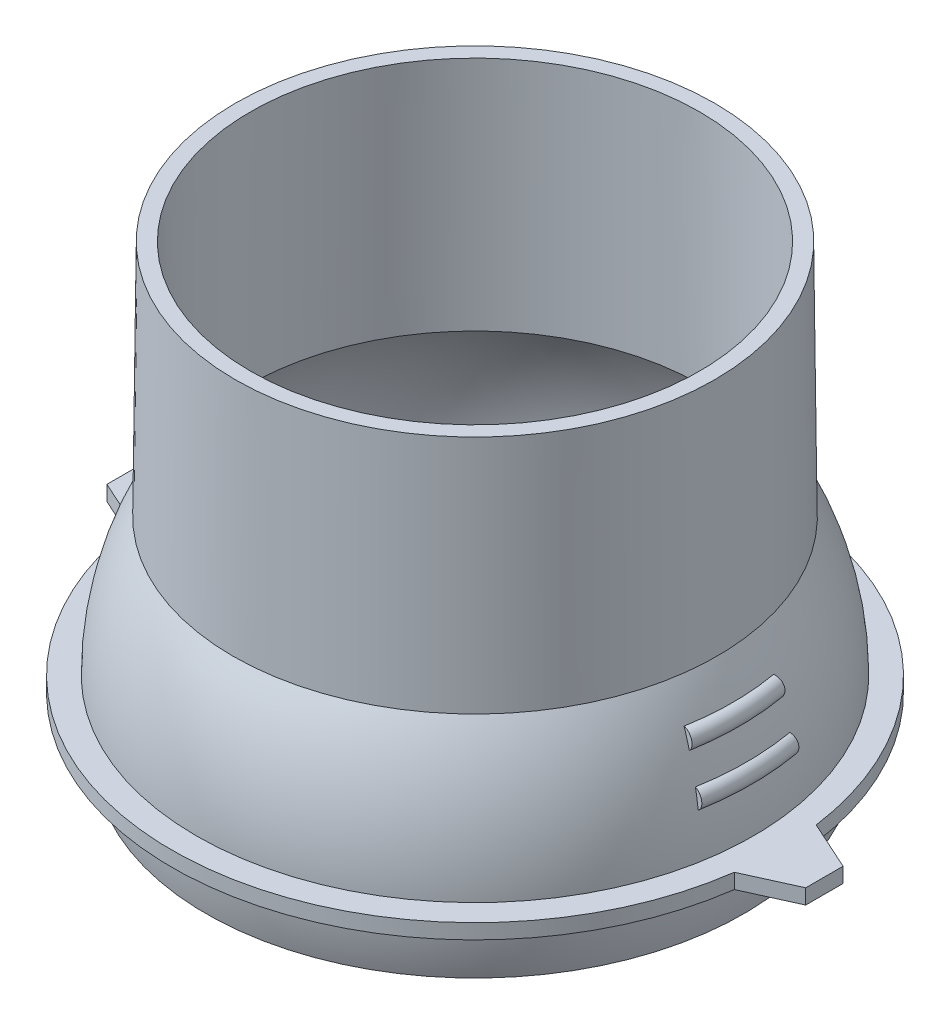
from build123d import *

# Parameters (mm, degrees)
BOSS_EXTRUDE1_DEPTH = 3
REVOLVE3_ANGLE      = 20


with BuildPart() as part:
    # Sketch2 → Revolve1 (revolve)
    with BuildSketch(Plane(origin=(0, 0, 0), x_dir=(0, 0, -1), z_dir=(1, 0, 0))):
        with BuildLine():
            Line((45.5, -47.702841719), (45, 0))
            Line((45, 0), (48, 0))
            Line((48, 0), (48.5, -47.702841719))
            ThreePointArc((48.5, -47.702841719), (55.331762509, -68.172170296), (53.883673101, -89.702832813))
            Line((53.883673101, -89.702832813), (51.12598641, -88.963912891))
            ThreePointArc((51.12598641, -88.963912891), (52.533458966, -67.757912773), (45.5, -47.702841719))
        make_face()
    revolve(axis=Axis((0, 50.355486862, 0), (0, -1, 0)))

    # Sketch3 → Revolve2 (revolve)
    with BuildSketch(Plane(origin=(0, 0, 0), x_dir=(0, 0, -1), z_dir=(1, 0, 0))):
        with BuildLine():
            Line((55.784483274, -75.26474612), (60.703757272, -75.26474612))
            Line((60.703757272, -75.26474612), (60.703757272, -78.26474612))
            Line((60.703757272, -78.26474612), (55.703757272, -78.26474612))
            ThreePointArc((55.703757272, -78.26474612), (55.764298122, -76.765289079), (55.784483274, -75.26474612))
        make_face()
    revolve(axis=Axis((0, -123.209470333, 0), (0, 1, 0)))

    # Sketch4 → Boss-Extrude1 (add)
    with BuildSketch(Plane(origin=(0, -75.26474612, 0), x_dir=(1, 0, 0), z_dir=(0, 1, 0))):
        with BuildLine():
            Line((70, 3.743582594), (70, -3.743582594))
            Line((70, -3.743582594), (60.146968721, -8.20294463))
            ThreePointArc((60.146968721, -8.20294463), (60.703757272, 0), (60.146968721, 8.20294463))
            Line((60.146968721, 8.20294463), (70, 3.743582594))
        make_face()
        with BuildLine():
            Line((-70, -3.743582594), (-60.146968721, -8.20294463))
            ThreePointArc((-60.146968721, -8.20294463), (-60.703757272, 0), (-60.146968721, 8.20294463))
            Line((-60.146968721, 8.20294463), (-70, 3.743582594))
            Line((-70, 3.743582594), (-70, -3.743582594))
        make_face()
    extrude(amount=-BOSS_EXTRUDE1_DEPTH)

    # Sketch5 → Revolve3 (revolve, symmetric)
    with BuildSketch(Plane.XY) as revolve3_sk:
        with BuildLine():
            ThreePointArc((51.641833573, -54.16902145), (53.482411948, -55.474645579), (52.935037783, -57.66388395))
            ThreePointArc((52.935037783, -57.66388395), (52.3176263, -55.905651292), (51.641833573, -54.16902145))
        make_face()
        with BuildLine():
            ThreePointArc((54.441970224, -63.100024488), (55.985518381, -64.683651003), (55.126394669, -66.721375297))
            ThreePointArc((55.126394669, -66.721375297), (54.814096651, -64.905046197), (54.441970224, -63.100024488))
        make_face()
    revolve3 = revolve(axis=Axis((0, -123.209470333, 0), (0, 1, 0)), revolution_arc=REVOLVE3_ANGLE / 2)
    revolve3 = revolve3 + revolve(revolve3_sk.sketch, axis=Axis((0, -123.209470333, 0), (0, -1, 0)), revolution_arc=REVOLVE3_ANGLE / 2)

    # Mirror1: Revolve3 across plane
    add(revolve3.mirror(Plane(origin=(0, 0, 0), x_dir=(0, 0, 1), z_dir=(1, 0, 0))))


solid = part.part
